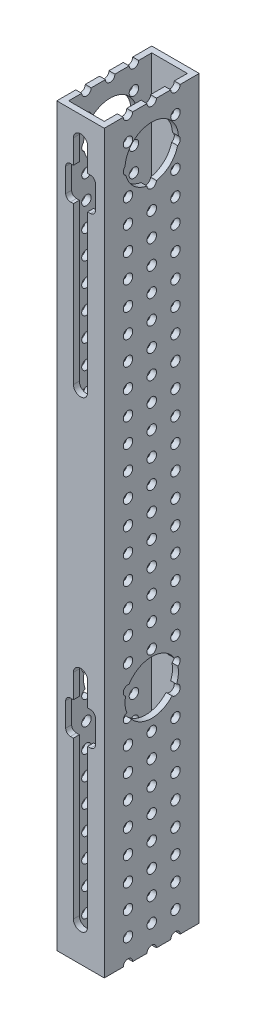
from build123d import *

# Parameters (mm, degrees)
SKETCH1_W            = 25.4
SKETCH1_H            = 50.8
BOSS_EXTRUDE1_DEPTH  = 419.1
SHELL1_T             = -3.175
CUT_EXTRUDE1_DEPTH   = 3.175
SKETCH3_R            = 14.2875
CUT_EXTRUDE2_DEPTH   = 26.4
CUT_EXTRUDE3_DEPTH   = 3.175
LPATTERN1_COUNT      = 2
LPATTERN1_PITCH      = 247.65
SKETCH6_R            = 2.54
CUT_EXTRUDE4_DEPTH   = 26.4
LPATTERN2_COUNT      = 33
LPATTERN2_PITCH      = 12.7
LPATTERN2_COUNT_DIR2 = 3
LPATTERN2_PITCH_DIR2 = 12.7
SKETCH7_W            = 25.4
SKETCH7_H            = 25.4
CUT_EXTRUDE5_DEPTH   = 50.8


with BuildPart() as part:
    # Sketch1 → Boss-Extrude1 (new body)
    with BuildSketch(Plane(origin=(0, 0, 0), x_dir=(1, 0, 0), z_dir=(0, 1, 0))):
        with Locations((12.7, 25.4)):
            Rectangle(SKETCH1_W, SKETCH1_H)
    extrude(amount=BOSS_EXTRUDE1_DEPTH)

    # Shell1
    shell1_openings = [part.faces().sort_by_distance(p)[0] for p in [
        (12.7, 419.1, -25.4),
        (12.7, 0, -25.4),
    ]]
    offset(amount=SHELL1_T, openings=shell1_openings, kind=Kind.INTERSECTION)

    # Sketch2 → Cut-Extrude1 (cut)
    with BuildSketch(Plane.XY):
        with BuildLine():
            Line((16.51, 406.4), (16.51, 292.1))
            ThreePointArc((16.51, 292.1), (12.7, 288.29), (8.89, 292.1))
            Line((8.89, 292.1), (8.89, 406.4))
            ThreePointArc((8.89, 406.4), (12.7, 410.21), (16.51, 406.4))
        make_face()
    cut_extrude1 = extrude(amount=-CUT_EXTRUDE1_DEPTH, mode=Mode.SUBTRACT)

    # Sketch3 → Cut-Extrude2 (cut, through all)
    with BuildSketch(Plane(origin=(25.4, 0, 0), x_dir=(0, 0, -1), z_dir=(1, 0, 0))):
        with Locations((25.4, 394.97)):
            Circle(SKETCH3_R)
    cut_extrude2 = extrude(amount=-CUT_EXTRUDE2_DEPTH, mode=Mode.SUBTRACT)

    # Sketch4 → Cut-Extrude3 (cut)
    with BuildSketch(Plane.XY):
        with BuildLine():
            Line((16.51, 393.7), (18.0975, 393.7))
            ThreePointArc((18.0975, 393.7), (19.893551224, 392.956051224), (20.6375, 391.16))
            Line((20.6375, 391.16), (20.6375, 378.46))
            ThreePointArc((20.6375, 378.46), (19.893551224, 376.663948776), (18.0975, 375.92))
            Line((18.0975, 375.92), (16.51, 375.92))
            Line((16.51, 375.92), (8.89, 375.92))
            Line((8.89, 375.92), (7.3025, 375.92))
            ThreePointArc((7.3025, 375.92), (5.506448776, 376.663948776), (4.7625, 378.46))
            Line((4.7625, 378.46), (4.7625, 391.16))
            ThreePointArc((4.7625, 391.16), (5.506448776, 392.956051224), (7.3025, 393.7))
            Line((7.3025, 393.7), (8.89, 393.7))
            Line((8.89, 393.7), (16.51, 393.7))
        make_face()
    cut_extrude3 = extrude(amount=-CUT_EXTRUDE3_DEPTH, mode=Mode.SUBTRACT)

    # LPattern1: Cut-Extrude1, Cut-Extrude2, Cut-Extrude3 ×2
    with Locations(*[(0, -i * LPATTERN1_PITCH, 0) for i in range(1, LPATTERN1_COUNT)]):
        add(cut_extrude1, mode=Mode.SUBTRACT)
        add(cut_extrude2, mode=Mode.SUBTRACT)
        add(cut_extrude3, mode=Mode.SUBTRACT)

    # Sketch6 → Cut-Extrude4 (cut, through all)
    with BuildSketch(Plane.ZY):
        with Locations((-38.1, 12.7)):
            Circle(SKETCH6_R)
    cut_extrude4 = extrude(amount=-CUT_EXTRUDE4_DEPTH, mode=Mode.SUBTRACT)

    # LPattern2: Cut-Extrude4 33 × 3
    with Locations(*[(0, i * LPATTERN2_PITCH, j * LPATTERN2_PITCH_DIR2) for i in range(LPATTERN2_COUNT) for j in range(LPATTERN2_COUNT_DIR2) if (i, j) != (0, 0)]):
        add(cut_extrude4, mode=Mode.SUBTRACT)

    # Sketch7 → Cut-Extrude5 (cut)
    with BuildSketch(Plane.XY):
        with Locations((12.7, 12.7)):
            Rectangle(SKETCH7_W, SKETCH7_H)
    extrude(amount=-CUT_EXTRUDE5_DEPTH, mode=Mode.SUBTRACT)


solid = part.part
